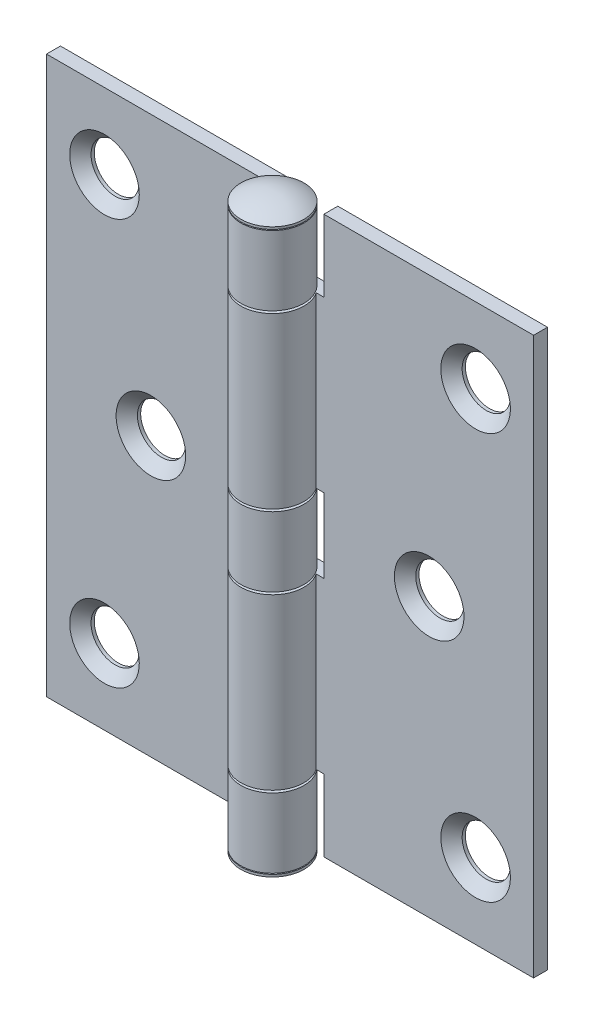
from build123d import *

# Parameters (mm, degrees)
BOSS_EXTRUDE1_START          = -4.318
SKETCH3_W                    = 33.3375
SKETCH3_H                    = 76.2
SKETCH3_R                    = 3.302
BOSS_EXTRUDE1_DEPTH          = 1.905
CUT_EXTRUDE_THIN1_DEPTH      = 51.661898224
CUT_EXTRUDE_THIN1_DEPTH_BACK = 51.661898224
CUT_EXTRUDE2_DEPTH           = 51.661898224
CUT_EXTRUDE2_DEPTH_BACK      = 51.661898224
SKETCH6_W                    = 33.3375
SKETCH6_H                    = 76.2
CUT_EXTRUDE3_DEPTH           = 51.661898224
CUT_EXTRUDE3_DEPTH_BACK      = 51.661898224
SKETCH7_W                    = 33.3375
SKETCH7_H                    = 76.2
SKETCH8_R                    = 4.318
BOSS_EXTRUDE2_DEPTH          = 9.525
SKETCH9_R                    = 4.318
BOSS_EXTRUDE3_DEPTH          = 9.525
SKETCH10_R                   = 4.318
BOSS_EXTRUDE4_DEPTH          = 9.525
SKETCH11_R                   = 4.318
BOSS_EXTRUDE5_DEPTH          = 23.1775
SKETCH12_R                   = 4.318
BOSS_EXTRUDE6_DEPTH          = 23.1775
BOSS_EXTRUDE8_START          = 0.127
SKETCH15_R                   = 4.318
BOSS_EXTRUDE8_DEPTH          = 0.3175
DOME1_FACE_RADIUS            = 4.318
DOME1_HEIGHT                 = 1.27
BOSS_EXTRUDE7_START          = -38.227
SKETCH13_R                   = 2.38125
BOSS_EXTRUDE7_DEPTH          = 76.454


with BuildPart() as part:
    # Sketch3 → Boss-Extrude1 (new body)
    with BuildSketch(Plane.XY.offset(BOSS_EXTRUDE1_START)):
        with Locations((-16.66875, 0)):
            Rectangle(SKETCH3_W, SKETCH3_H)
        with Locations((-25.4, 27.78125)):
            Circle(SKETCH3_R, mode=Mode.SUBTRACT)
        with Locations((-19.05, 0)):
            Circle(SKETCH3_R, mode=Mode.SUBTRACT)
        with Locations((-25.4, -27.78125)):
            Circle(SKETCH3_R, mode=Mode.SUBTRACT)
    extrude(amount=BOSS_EXTRUDE1_DEPTH)

    # Cut-Extrude1 cone 1 section (through the dimple's axis) → Cut-Extrude1 (revolve, cut)
    with BuildSketch(Plane(origin=(-25.4, 27.78125, -2.413), x_dir=(0, -1, 0), z_dir=(1, 0, 0))):
        Polygon((0, 0), (4.7625, 0), (0, 4.7625), align=None)
    revolve(axis=Axis((-25.4, 27.78125, -2.413), (0, 0, -1)), mode=Mode.SUBTRACT)

    # Cut-Extrude1 cone 2 section (through the dimple's axis) → Cut-Extrude1 cone 2 (revolve, cut)
    with BuildSketch(Plane(origin=(-19.05, 0, -2.413), x_dir=(0, -1, 0), z_dir=(1, 0, 0))):
        Polygon((0, 0), (4.7625, 0), (0, 4.7625), align=None)
    revolve(axis=Axis((-19.05, 0, -2.413), (0, 0, -1)), mode=Mode.SUBTRACT)

    # Cut-Extrude1 cone 3 section (through the dimple's axis) → Cut-Extrude1 cone 3 (revolve, cut)
    with BuildSketch(Plane(origin=(-25.4, -27.78125, -2.413), x_dir=(0, -1, 0), z_dir=(1, 0, 0))):
        Polygon((0, 0), (4.7625, 0), (0, 4.7625), align=None)
    revolve(axis=Axis((-25.4, -27.78125, -2.413), (0, 0, -1)), mode=Mode.SUBTRACT)

    # Mirror1: part across plane


with BuildPart() as part_1:
    add(part.part)
    add(part.part.mirror(Plane(origin=(0, 0, 0), x_dir=(0, 0, 1), z_dir=(1, 0, 0))))

    # Sketch5 → Cut-Extrude-Thin1 (cut, two sides: drawn at the far end of the back side and taken through both)
    with BuildSketch(Plane.XY.offset(-2.413).offset(-CUT_EXTRUDE_THIN1_DEPTH_BACK)):
        Polygon((4.318, 38.1), (4.318, 28.575), (-4.6355, 28.575), (-4.6355, 4.7625), (4.318, 4.7625), (4.318, 0), (4.318, -4.7625), (-4.6355, -4.7625), (-4.6355, -28.575), (4.318, -28.575), (4.318, -38.1), (4.6355, -38.1), (4.6355, -28.2575), (-4.318, -28.2575), (-4.318, -5.08), (4.6355, -5.08), (4.6355, 0), (4.6355, 5.08), (-4.318, 5.08), (-4.318, 28.2575), (4.6355, 28.2575), (4.6355, 38.1), align=None)
    extrude(amount=CUT_EXTRUDE_THIN1_DEPTH + CUT_EXTRUDE_THIN1_DEPTH_BACK, mode=Mode.SUBTRACT)


with BuildPart() as cut_extrude_thin1_piece_1:
    # of the separate pieces the step leaves, piece 1, a body of its own (cut_extrude_thin1_pieces)
    add(part_1.part.solids().sort_by_distance((4.6355, 38.1, -4.318))[0])

    # Sketch6 → Cut-Extrude2 (cut, two sides: drawn at the far end of the back side and taken through both)
    with BuildSketch(Plane.XY.offset(-2.413).offset(-CUT_EXTRUDE2_DEPTH_BACK)):
        with Locations((-16.66875, 0)):
            Rectangle(SKETCH6_W, SKETCH6_H)
    extrude(amount=CUT_EXTRUDE2_DEPTH + CUT_EXTRUDE2_DEPTH_BACK, mode=Mode.SUBTRACT)

    # Sketch11 → Boss-Extrude5 (add)
    with BuildSketch(Plane.XZ.offset(28.2575)):
        Circle(SKETCH11_R)
    extrude(amount=-BOSS_EXTRUDE5_DEPTH)

    # Sketch12 → Boss-Extrude6 (add)
    with BuildSketch(Plane(origin=(0, 28.2575, 0), x_dir=(1, 0, 0), z_dir=(0, 1, 0))):
        Circle(SKETCH12_R)
    extrude(amount=-BOSS_EXTRUDE6_DEPTH)



with BuildPart() as cut_extrude_thin1_piece_2:
    # of the separate pieces the step leaves, piece 2, a body of its own (cut_extrude_thin1_pieces)
    add(part_1.part.solids().sort_by_distance((-33.3375, 38.1, -4.318))[0])

    # Sketch7 → Cut-Extrude3 (cut, two sides: drawn at the far end of the back side and taken through both)
    with BuildSketch(Plane.XY.offset(-2.413).offset(-CUT_EXTRUDE3_DEPTH_BACK)):
        with Locations((16.66875, 0)):
            Rectangle(SKETCH7_W, SKETCH7_H)
    extrude(amount=CUT_EXTRUDE3_DEPTH + CUT_EXTRUDE3_DEPTH_BACK, mode=Mode.SUBTRACT)

    # Sketch8 → Boss-Extrude2 (add)
    with BuildSketch(Plane.XZ.offset(38.1)):
        Circle(SKETCH8_R)
    extrude(amount=-BOSS_EXTRUDE2_DEPTH)

    # Sketch9 → Boss-Extrude3 (add)
    with BuildSketch(Plane.XZ.offset(4.7625)):
        Circle(SKETCH9_R)
    extrude(amount=-BOSS_EXTRUDE3_DEPTH)

    # Sketch10 → Boss-Extrude4 (add)
    with BuildSketch(Plane.XZ.offset(-28.575)):
        Circle(SKETCH10_R)
    extrude(amount=-BOSS_EXTRUDE4_DEPTH)


with BuildPart() as body_3:
    # Sketch15 → Boss-Extrude8 (new body)
    with BuildSketch(Plane(origin=(0, 38.1, 0), x_dir=(1, 0, 0), z_dir=(0, 1, 0)).offset(BOSS_EXTRUDE8_START)):
        with Locations(Location((0, 0, 0), (0, 0, 270))):
            Circle(SKETCH15_R)
    extrude(amount=BOSS_EXTRUDE8_DEPTH)

    # Dome1: a dome of height H over a round flat face of radius A is a cap of a sphere of radius (A * A + H * H) / (2 * H)
    dome1_r = (DOME1_FACE_RADIUS * DOME1_FACE_RADIUS + DOME1_HEIGHT * DOME1_HEIGHT) / (2 * DOME1_HEIGHT)
    dome1_base = Plane((0, 38.5445, 0), z_dir=(0, 1, 0))
    with Locations(dome1_base.offset(DOME1_HEIGHT - dome1_r)):
        dome1_ball = Sphere(dome1_r, mode=Mode.PRIVATE)
    add(split(dome1_ball, bisect_by=dome1_base, keep=Keep.TOP, mode=Mode.PRIVATE))


with BuildPart() as body_4:
    # Mirror2: mirrored copy
    add(body_3.part.mirror(Plane.ZX))


with BuildPart() as cut_extrude_thin1_piece_1_1:
    add(cut_extrude_thin1_piece_1.part)

    add(cut_extrude_thin1_piece_2.part)  # Boss-Extrude7 merges Cut-Extrude-Thin1 piece 2

    add(body_3.part)  # Boss-Extrude7 merges body 3

    add(body_4.part)  # Boss-Extrude7 merges body 4
    # Sketch13 → Boss-Extrude7 (add)
    with BuildSketch(Plane(origin=(0, 0, 0), x_dir=(1, 0, 0), z_dir=(0, 1, 0)).offset(BOSS_EXTRUDE7_START)):
        with Locations(Location((0, 0, 0), (0, 0, 270))):
            Circle(SKETCH13_R)
    extrude(amount=BOSS_EXTRUDE7_DEPTH)


solid = cut_extrude_thin1_piece_1_1.part
